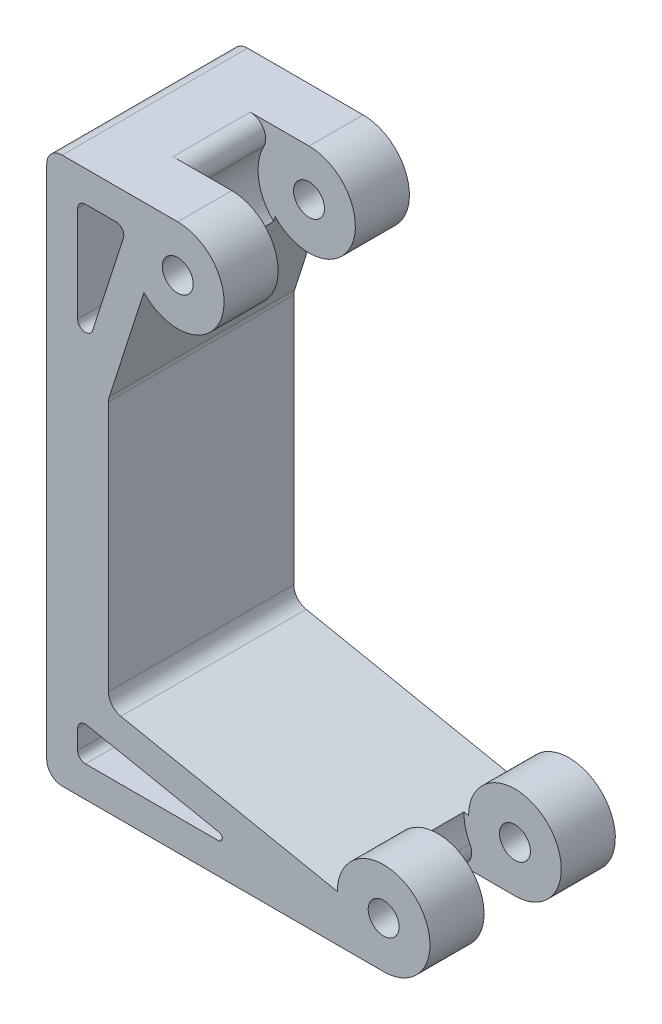
from build123d import *

# Parameters (mm, degrees)
SKETCH1_R               = 1
BOSS_EXTRUDE1_DEPTH     = 12
SKETCH2_R               = 3.3
CUT_EXTRUDE1_DEPTH      = 2.5
CUT_EXTRUDE1_DEPTH_BACK = 2.5
FILLET1_R               = 1
FILLET2_R               = 1
FILLET3_R               = 1
FILLET4_R               = 0.5
FILLET5_R               = 0.25


with BuildPart() as part:
    # Sketch1 → Boss-Extrude1 (new body)
    with BuildSketch(Plane.XY):
        with BuildLine():
            Line((0, 0), (21.817354946, 0))
            ThreePointArc((21.817354946, 0), (23.938675289, 5.121320344), (18.817354946, 3))
            Line((18.817354946, 3), (4, 5.97347684))
            Line((4, 5.97347684), (4, 23.200108131))
            Line((4, 23.200108131), (6.297593783, 30.327226275))
            ThreePointArc((6.297593783, 30.327226275), (11.237097985, 31.191049803), (8.483562347, 35.381865278))
            Line((8.483562347, 35.381865278), (0, 35.381865278))
            Line((0, 35.381865278), (0, 0))
        make_face()
        with Locations((8.483562347, 32.381865278)):
            Circle(SKETCH1_R, mode=Mode.SUBTRACT)
        with Locations((21.817354946, 3)):
            Circle(SKETCH1_R, mode=Mode.SUBTRACT)
        Polygon((5.180971974, 33.381865278), (2, 33.381865278), (2, 23.514514817), align=None, mode=Mode.SUBTRACT)
        Polygon((2, 2), (2, 4.334954297), (13.63548548, 2), align=None, mode=Mode.SUBTRACT)
    extrude(amount=BOSS_EXTRUDE1_DEPTH)

    # Sketch2 → Cut-Extrude1 (cut, two sides)
    with BuildSketch(Plane.XY.offset(6)) as cut_extrude1_sk:
        with Locations((8.483562347, 32.381865278)):
            Circle(SKETCH2_R)
        with Locations((21.817354946, 3)):
            Circle(SKETCH2_R)
    extrude(amount=CUT_EXTRUDE1_DEPTH, mode=Mode.SUBTRACT)
    extrude(cut_extrude1_sk.sketch, amount=-CUT_EXTRUDE1_DEPTH_BACK, mode=Mode.SUBTRACT)

    # Fillet1
    fillet1_edges = [part.edges().sort_by_distance(p)[0] for p in [
        (0, 35.381865278, 6),
        (0, 0, 6),
    ]]
    fillet(fillet1_edges, radius=FILLET1_R)

    # Fillet2
    fillet2_edges = [part.edges().sort_by_distance(p)[0] for p in [
        (4, 23.200108131, 6),
        (4, 5.97347684, 6),
    ]]
    fillet(fillet2_edges, radius=FILLET2_R)

    # Fillet3
    fillet3_edges = [part.edges().sort_by_distance(p)[0] for p in [
        (7.108789639, 35.381865278, 6),
        (20.442582237, 0, 6),
    ]]
    fillet(fillet3_edges, radius=FILLET3_R)

    # Fillet4
    fillet4_edges = [part.edges().sort_by_distance(p)[0] for p in [
        (2, 2, 6),
        (2, 4.334954297, 6),
        (2, 23.514514817, 6),
        (5.180971974, 33.381865278, 6),
        (2, 33.381865278, 6),
    ]]
    fillet(fillet4_edges, radius=FILLET4_R)

    # Fillet5
    fillet5_edges = [part.edges().sort_by_distance(p)[0] for p in [
        (13.63548548, 2, 6),
    ]]
    fillet(fillet5_edges, radius=FILLET5_R)


solid = part.part
